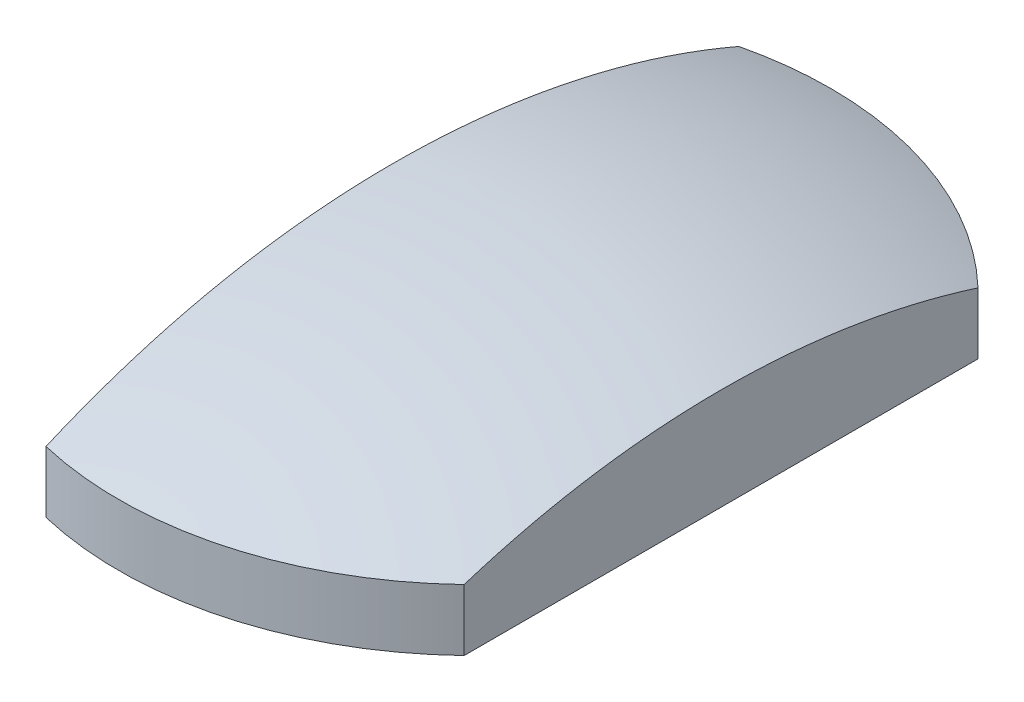
from build123d import *

# Parameters (mm, degrees)
SKETCH_2_OUTSIDE_W       = 35.526
SKETCH_2_OUTSIDE_H       = 35.526
SKETCH_2_OUTSIDE_W_2     = 12
SKETCH_2_OUTSIDE_H_2     = 28
CUT_EXTRUDE_1_DEPTH      = 9
SKETCH_3_W               = 30
SKETCH_3_H               = 3
CUT_EXTRUDE_2_DEPTH      = 10
CUT_EXTRUDE_2_DEPTH_BACK = 4


with BuildPart() as part:
    # Эскиз1 → Повернуть1 (revolve)
    with BuildSketch(Plane(origin=(0, 0, 0), x_dir=(0, 0, -1), z_dir=(1, 0, 0))):
        with BuildLine():
            Line((13, 1.217734844), (13, 5.246033508))
            ThreePointArc((13, 5.246033508), (6.644251866, 7.303952511), (0, 8))
            Line((0, 8), (0, 0))
            ThreePointArc((0, 0), (6.528454606, 0.305098605), (13, 1.217734844))
        make_face()
    revolve(axis=Axis((0, 8, 0), (0, -1, 0)))

    # Эскиз2 outside → Вырез-Вытянуть1 (cut, through all)
    with BuildSketch(Plane.XZ.offset(-8)):
        Rectangle(SKETCH_2_OUTSIDE_W, SKETCH_2_OUTSIDE_H)
        with Locations((3, 0)):
            Rectangle(SKETCH_2_OUTSIDE_W_2, SKETCH_2_OUTSIDE_H_2, mode=Mode.SUBTRACT)
    extrude(amount=CUT_EXTRUDE_1_DEPTH, mode=Mode.SUBTRACT)

    # Эскиз3 → Вырез-Вытянуть2 (cut, two sides)
    with BuildSketch(Plane(origin=(0, 0, 0), x_dir=(0, 0, -1), z_dir=(1, 0, 0))) as cut_extrude_2_sk:
        with Locations((0, 1.5)):
            Rectangle(SKETCH_3_W, SKETCH_3_H)
    extrude(amount=CUT_EXTRUDE_2_DEPTH, mode=Mode.SUBTRACT)
    extrude(cut_extrude_2_sk.sketch, amount=-CUT_EXTRUDE_2_DEPTH_BACK, mode=Mode.SUBTRACT)


solid = part.part
